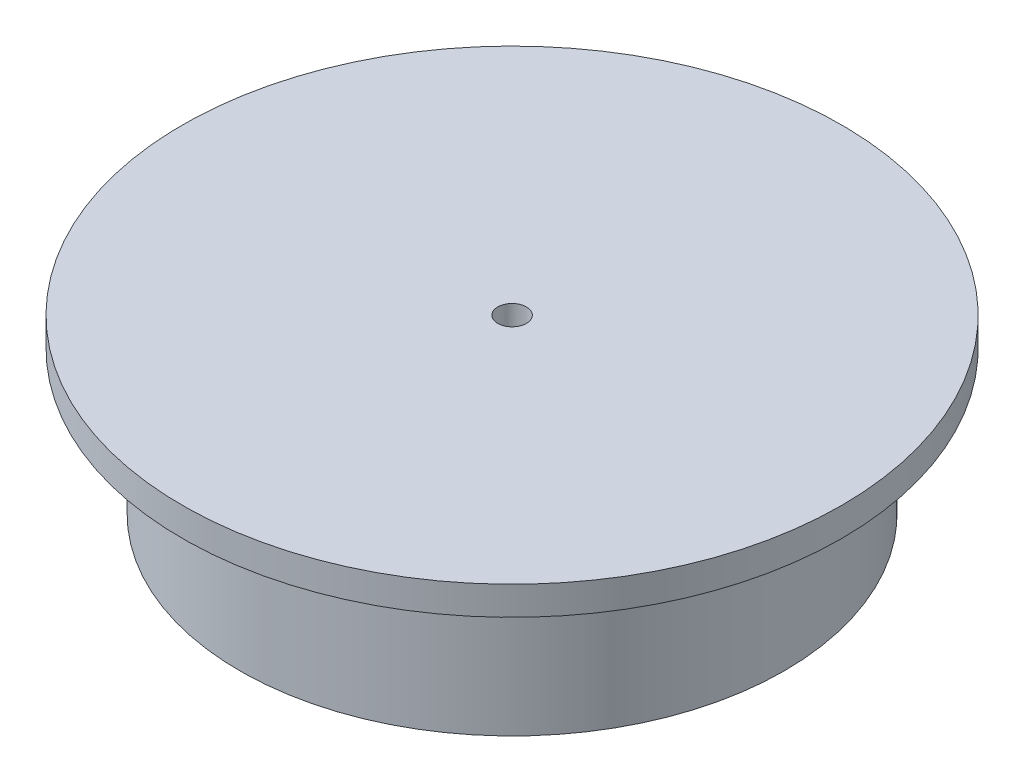
from build123d import *

# Parameters (mm, degrees)
SKETCH2_R          = 2.5
CUT_EXTRUDE1_DEPTH = 40


with BuildPart() as part:
    # Sketch1 → Revolve1 (revolve)
    with BuildSketch(Plane.XY):
        Polygon((0, 10), (-2.5, 10), (-12.682056098, 20.182056098), (-22.5, 10.364112197), (-32.623909355, 20.488021552), (-42.5, 10.611930908), (-47.5, 10.611930908), (-47.5, 35.611930908), (-57.5, 35.611930908), (-57.5, 40.611930908), (0, 40.611930908), align=None)
    revolve(axis=Axis((0, 40.611930908, 0), (0, 1, 0)))

    # Sketch2 → Cut-Extrude1 (cut)
    with BuildSketch(Plane.XZ.offset(-10)):
        Circle(SKETCH2_R)
    extrude(amount=-CUT_EXTRUDE1_DEPTH, mode=Mode.SUBTRACT)


solid = part.part
